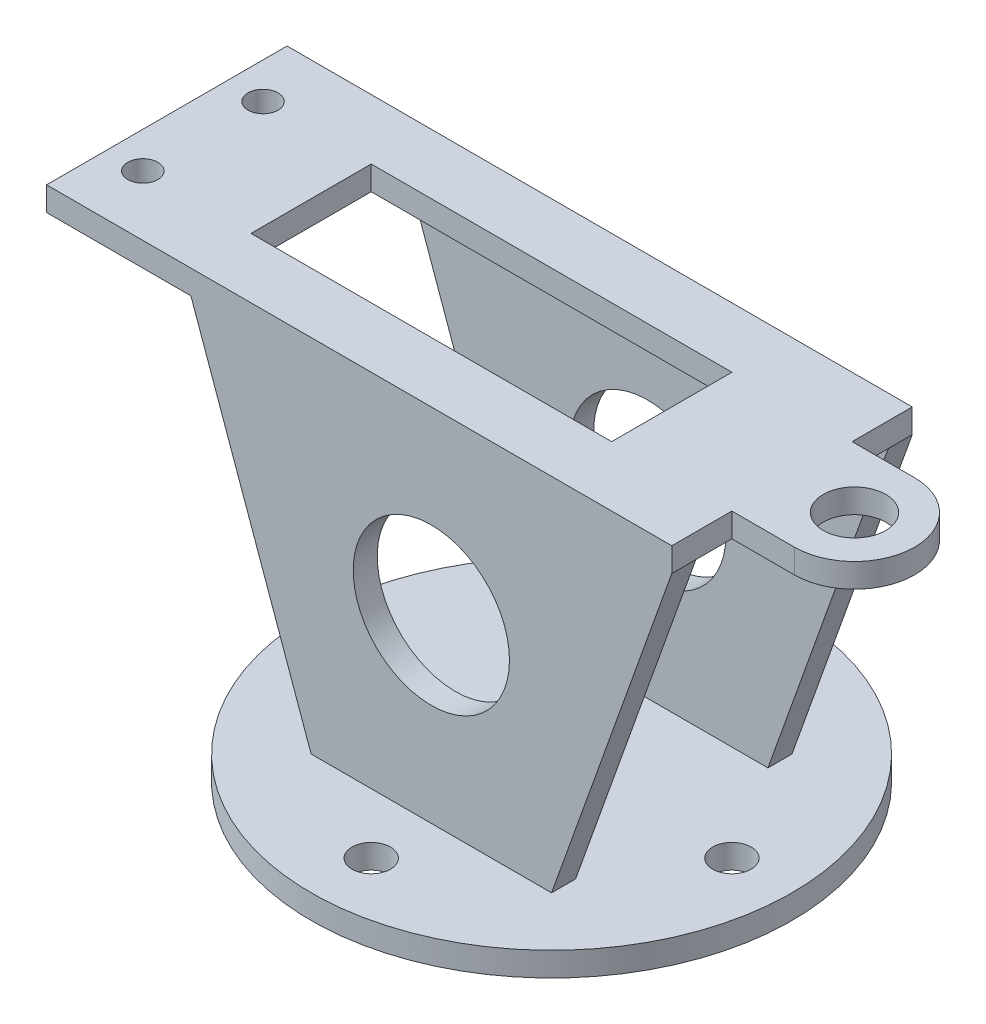
from build123d import *

# Parameters (mm, degrees)
BOSS_EXTRUDE1_DEPTH = 50.8
SKETCH2_W           = 30.48
SKETCH2_H           = 50.8
SKETCH2_R           = 3.175
SKETCH2_R_2         = 6.604
BOSS_EXTRUDE2_DEPTH = 5.08
SKETCH3_W           = 76.2
SKETCH3_H           = 25.4
CUT_EXTRUDE1_DEPTH  = 77.2
CUT_EXTRUDE2_DEPTH  = 51.8
BOSS_EXTRUDE3_DEPTH = 5.08
SKETCH6_R           = 16.51
CUT_EXTRUDE3_DEPTH  = 77.2


with BuildPart() as part:
    # Sketch1 → Boss-Extrude1 (new body, symmetric)
    with BuildSketch(Plane(origin=(0, 0, 0), x_dir=(0, 0, -1), z_dir=(1, 0, 0))):
        Polygon((-25.4, 0), (-20.32, 0), (-20.32, 71.12), (0, 71.12), (0, 76.2), (-25.4, 76.2), (-25.4, 71.12), align=None)
        Polygon((0, 76.2), (0, 71.12), (20.32, 71.12), (20.32, 0), (25.4, 0), (25.4, 71.12), (25.4, 76.2), align=None)
    extrude(amount=BOSS_EXTRUDE1_DEPTH, both=True)

    # Sketch2 → Boss-Extrude2 (add)
    with BuildSketch(Plane(origin=(0, 76.2, 0), x_dir=(1, 0, 0), z_dir=(0, 1, 0))):
        with Locations((-66.04, 0)):
            Rectangle(SKETCH2_W, SKETCH2_H)
        with Locations((-73.66, -12.7)):
            Circle(SKETCH2_R, mode=Mode.SUBTRACT)
        with Locations((-73.66, 12.7)):
            Circle(SKETCH2_R, mode=Mode.SUBTRACT)
        with BuildLine():
            Line((64.008, 12.7), (50.8, 12.7))
            Line((50.8, 12.7), (50.8, -12.7))
            Line((50.8, -12.7), (64.008, -12.7))
            ThreePointArc((64.008, -12.7), (76.708, 0), (64.008, 12.7))
        make_face()
        with Locations((64.008, 0)):
            Circle(SKETCH2_R_2, mode=Mode.SUBTRACT)
    extrude(amount=-BOSS_EXTRUDE2_DEPTH)

    # Sketch3 → Cut-Extrude1 (cut, through all)
    with BuildSketch(Plane(origin=(0, 76.2, 0), x_dir=(1, 0, 0), z_dir=(0, 1, 0))):
        with Locations((-12.7, 0)):
            Rectangle(SKETCH3_W, SKETCH3_H)
    extrude(amount=-CUT_EXTRUDE1_DEPTH, mode=Mode.SUBTRACT)

    # Sketch5 → Cut-Extrude2 (cut, through all)
    with BuildSketch(Plane.XY.offset(25.4)):
        Polygon((-25.4, 0), (-50.8, 71.12), (-50.8, 0), align=None)
        Polygon((50.8, 71.12), (25.4, 0), (50.8, 0), align=None)
    extrude(amount=-CUT_EXTRUDE2_DEPTH, mode=Mode.SUBTRACT)

    # Sketch4 → Boss-Extrude3 (add)
    with BuildSketch(Plane(origin=(0, 0, 0), x_dir=(-1, 0, 0), z_dir=(0, -1, 0))):
        with BuildLine():
            Line((-28.398063314, -25.4), (-43.994090512, -25.4))
            ThreePointArc((-43.994090512, -25.4), (0, -50.8), (43.994090512, -25.4))
            Line((43.994090512, -25.4), (28.398063314, -25.4))
            ThreePointArc((28.398063314, -25.4), (17.387076227, -33.901321217), (4.058215973, -37.883253333))
            ThreePointArc((4.058215973, -37.883253333), (4.062553736, -37.991588086), (4.064, -38.1))
            ThreePointArc((4.064, -38.1), (-0.108411914, -42.162553736), (-4.058215973, -37.883253333))
            ThreePointArc((-4.058215973, -37.883253333), (-17.387076227, -33.901321217), (-28.398063314, -25.4))
        make_face()
        with BuildLine():
            ThreePointArc((46.558969061, -20.32), (49.728440697, -10.378929899), (50.8, 0))
            ThreePointArc((50.8, 0), (-10.378929899, 49.728440697), (-46.558969061, -20.32))
            Line((-46.558969061, -20.32), (-32.228986953, -20.32))
            ThreePointArc((-32.228986953, -20.32), (-35.986705384, -12.512674997), (-37.883253333, -4.058215973))
            ThreePointArc((-37.883253333, -4.058215973), (-42.164, 0), (-37.883253333, 4.058215973))
            ThreePointArc((-37.883253333, 4.058215973), (-26.940768363, 26.940768363), (-4.058215973, 37.883253333))
            ThreePointArc((-4.058215973, 37.883253333), (-0.108411914, 42.162553736), (4.064, 38.1))
            ThreePointArc((4.064, 38.1), (4.062553736, 37.991588086), (4.058215973, 37.883253333))
            ThreePointArc((4.058215973, 37.883253333), (26.940768363, 26.940768363), (37.883253333, 4.058215973))
            ThreePointArc((37.883253333, 4.058215973), (40.896000496, 2.949318095), (42.164, 0))
            ThreePointArc((42.164, 0), (40.896000496, -2.949318095), (37.883253333, -4.058215973))
            ThreePointArc((37.883253333, -4.058215973), (35.986705384, -12.512674997), (32.228986953, -20.32))
            Line((32.228986953, -20.32), (46.558969061, -20.32))
        make_face()
        with BuildLine():
            ThreePointArc((-37.883253333, -4.058215973), (-35.986705384, -12.512674997), (-32.228986953, -20.32))
            Line((-32.228986953, -20.32), (32.228986953, -20.32))
            ThreePointArc((32.228986953, -20.32), (35.986705384, -12.512674997), (37.883253333, -4.058215973))
            ThreePointArc((37.883253333, -4.058215973), (34.036, 0), (37.883253333, 4.058215973))
            ThreePointArc((37.883253333, 4.058215973), (26.940768363, 26.940768363), (4.058215973, 37.883253333))
            ThreePointArc((4.058215973, 37.883253333), (0, 34.036), (-4.058215973, 37.883253333))
            ThreePointArc((-4.058215973, 37.883253333), (-26.940768363, 26.940768363), (-37.883253333, 4.058215973))
            ThreePointArc((-37.883253333, 4.058215973), (-35.150681905, 2.796000496), (-34.036, 0))
            ThreePointArc((-34.036, 0), (-35.150681905, -2.796000496), (-37.883253333, -4.058215973))
        make_face()
        with BuildLine():
            Line((-32.228986953, -20.32), (-46.558969061, -20.32))
            ThreePointArc((-46.558969061, -20.32), (-45.347720444, -22.895943975), (-43.994090512, -25.4))
            Line((-43.994090512, -25.4), (-28.398063314, -25.4))
            ThreePointArc((-28.398063314, -25.4), (-30.41975355, -22.940108848), (-32.228986953, -20.32))
        make_face()
        with BuildLine():
            ThreePointArc((43.994090512, -25.4), (45.347720444, -22.895943975), (46.558969061, -20.32))
            Line((46.558969061, -20.32), (32.228986953, -20.32))
            ThreePointArc((32.228986953, -20.32), (30.41975355, -22.940108848), (28.398063314, -25.4))
            Line((28.398063314, -25.4), (43.994090512, -25.4))
        make_face()
        with BuildLine():
            Line((28.398063314, -25.4), (-28.398063314, -25.4))
            ThreePointArc((-28.398063314, -25.4), (-17.387076227, -33.901321217), (-4.058215973, -37.883253333))
            ThreePointArc((-4.058215973, -37.883253333), (0, -34.036), (4.058215973, -37.883253333))
            ThreePointArc((4.058215973, -37.883253333), (17.387076227, -33.901321217), (28.398063314, -25.4))
        make_face()
        with BuildLine():
            Line((32.228986953, -20.32), (-32.228986953, -20.32))
            ThreePointArc((-32.228986953, -20.32), (-30.41975355, -22.940108848), (-28.398063314, -25.4))
            Line((-28.398063314, -25.4), (28.398063314, -25.4))
            ThreePointArc((28.398063314, -25.4), (30.41975355, -22.940108848), (32.228986953, -20.32))
        make_face()
    extrude(amount=BOSS_EXTRUDE3_DEPTH)

    # Sketch6 → Cut-Extrude3 (cut, through all)
    with BuildSketch(Plane.XY.offset(25.4)):
        with Locations((0, 38.1)):
            Circle(SKETCH6_R)
    extrude(amount=-CUT_EXTRUDE3_DEPTH, mode=Mode.SUBTRACT)


solid = part.part
